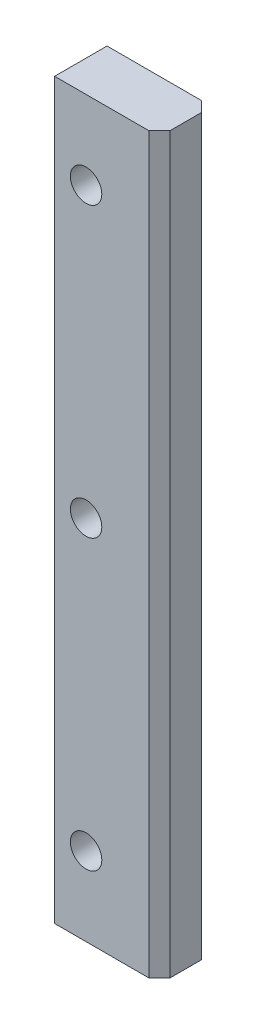
from build123d import *

# Parameters (mm, degrees)
SKETCH1_W           = 20
SKETCH1_H           = 140
BOSS_EXTRUDE1_DEPTH = 10
CHAMFER1_SIZE       = 2
SKETCH2_R           = 3
CUT_EXTRUDE1_DEPTH  = 11


with BuildPart() as part:
    # Sketch1 → Boss-Extrude1 (new body)
    with BuildSketch(Plane.XY):
        Rectangle(SKETCH1_W, SKETCH1_H)
    extrude(amount=BOSS_EXTRUDE1_DEPTH)

    # Chamfer1
    chamfer1_edges = [part.edges().sort_by_distance(p)[0] for p in [
        (10, 0, 0),
        (10, 0, 10),
    ]]
    chamfer(chamfer1_edges, length=CHAMFER1_SIZE)

    # Sketch2 → Cut-Extrude1 (cut, through all)
    with BuildSketch(Plane.XY.offset(10)):
        with Locations((-4, 55)):
            Circle(SKETCH2_R)
        with Locations((-4, 0)):
            Circle(SKETCH2_R)
        with Locations((-4, -55)):
            Circle(SKETCH2_R)
    extrude(amount=-CUT_EXTRUDE1_DEPTH, mode=Mode.SUBTRACT)


solid = part.part
